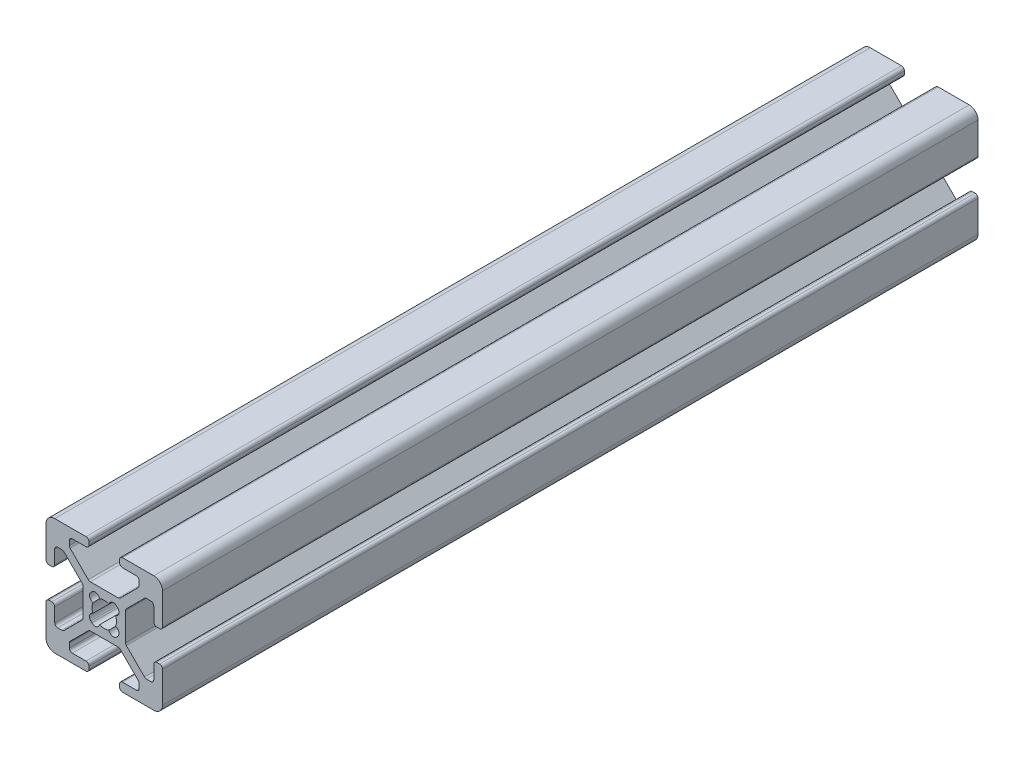
from build123d import *

# Parameters (mm, degrees)
BOSS_EXTRUDE1_DEPTH = 140


with BuildPart() as part:
    # Sketch1 → Boss-Extrude1 (new body)
    with BuildSketch(Plane.XY.offset(4000)):
        with BuildLine():
            Line((10, 3.138), (10, 8.5))
            ThreePointArc((10, 8.5), (9.560660172, 9.560660172), (8.5, 10))
            Line((8.5, 10), (3.138, 10))
            ThreePointArc((3.138, 10), (2.778789755, 9.851210245), (2.63, 9.492))
            Line((2.63, 9.492), (2.63, 9.008))
            ThreePointArc((2.63, 9.008), (2.778789755, 8.648789755), (3.138, 8.5))
            Line((3.138, 8.5), (5.487, 8.5))
            ThreePointArc((5.487, 8.5), (5.846210245, 8.351210245), (5.995, 7.992))
            Line((5.995, 7.992), (5.995, 7.266080661))
            ThreePointArc((5.995, 7.266080661), (5.956330803, 7.071677478), (5.846210245, 6.906870417))
            Line((5.846210245, 6.906870417), (2.743129583, 3.803789755))
            ThreePointArc((2.743129583, 3.803789755), (2.578322522, 3.693669197), (2.383919339, 3.655))
            Line((2.383919339, 3.655), (-2.383919339, 3.655))
            ThreePointArc((-2.383919339, 3.655), (-2.578322522, 3.693669197), (-2.743129583, 3.803789755))
            Line((-2.743129583, 3.803789755), (-5.846210245, 6.906870417))
            ThreePointArc((-5.846210245, 6.906870417), (-5.956330803, 7.071677478), (-5.995, 7.266080661))
            Line((-5.995, 7.266080661), (-5.995, 7.992))
            ThreePointArc((-5.995, 7.992), (-5.846210245, 8.351210245), (-5.487, 8.5))
            Line((-5.487, 8.5), (-3.138, 8.5))
            ThreePointArc((-3.138, 8.5), (-2.778789755, 8.648789755), (-2.63, 9.008))
            Line((-2.63, 9.008), (-2.63, 9.492))
            ThreePointArc((-2.63, 9.492), (-2.778789755, 9.851210245), (-3.138, 10))
            Line((-3.138, 10), (-8.5, 10))
            ThreePointArc((-8.5, 10), (-9.560660172, 9.560660172), (-10, 8.5))
            Line((-10, 8.5), (-10, 3.138))
            ThreePointArc((-10, 3.138), (-9.851210245, 2.778789755), (-9.492, 2.63))
            Line((-9.492, 2.63), (-9.008, 2.63))
            ThreePointArc((-9.008, 2.63), (-8.648789755, 2.778789755), (-8.5, 3.138))
            Line((-8.5, 3.138), (-8.5, 5.487))
            ThreePointArc((-8.5, 5.487), (-8.351210245, 5.846210245), (-7.992, 5.995))
            Line((-7.992, 5.995), (-7.266080661, 5.995))
            ThreePointArc((-7.266080661, 5.995), (-7.071677478, 5.956330803), (-6.906870417, 5.846210245))
            Line((-6.906870417, 5.846210245), (-3.803789755, 2.743129583))
            ThreePointArc((-3.803789755, 2.743129583), (-3.693669197, 2.578322522), (-3.655, 2.383919339))
            Line((-3.655, 2.383919339), (-3.655, -2.383919339))
            ThreePointArc((-3.655, -2.383919339), (-3.693669197, -2.578322522), (-3.803789755, -2.743129583))
            Line((-3.803789755, -2.743129583), (-6.906870417, -5.846210245))
            ThreePointArc((-6.906870417, -5.846210245), (-7.071677478, -5.956330803), (-7.266080661, -5.995))
            Line((-7.266080661, -5.995), (-7.992, -5.995))
            ThreePointArc((-7.992, -5.995), (-8.351210245, -5.846210245), (-8.5, -5.487))
            Line((-8.5, -5.487), (-8.5, -3.138))
            ThreePointArc((-8.5, -3.138), (-8.648789755, -2.778789755), (-9.008, -2.63))
            Line((-9.008, -2.63), (-9.492, -2.63))
            ThreePointArc((-9.492, -2.63), (-9.851210245, -2.778789755), (-10, -3.138))
            Line((-10, -3.138), (-10, -8.5))
            ThreePointArc((-10, -8.5), (-9.560660172, -9.560660172), (-8.5, -10))
            Line((-8.5, -10), (-3.138, -10))
            ThreePointArc((-3.138, -10), (-2.778789755, -9.851210245), (-2.63, -9.492))
            Line((-2.63, -9.492), (-2.63, -9.008))
            ThreePointArc((-2.63, -9.008), (-2.778789755, -8.648789755), (-3.138, -8.5))
            Line((-3.138, -8.5), (-5.487, -8.5))
            ThreePointArc((-5.487, -8.5), (-5.846210245, -8.351210245), (-5.995, -7.992))
            Line((-5.995, -7.992), (-5.995, -7.266080661))
            ThreePointArc((-5.995, -7.266080661), (-5.956330803, -7.071677478), (-5.846210245, -6.906870417))
            Line((-5.846210245, -6.906870417), (-2.743129583, -3.803789755))
            ThreePointArc((-2.743129583, -3.803789755), (-2.578322522, -3.693669197), (-2.383919339, -3.655))
            Line((-2.383919339, -3.655), (2.383919339, -3.655))
            ThreePointArc((2.383919339, -3.655), (2.578322522, -3.693669197), (2.743129583, -3.803789755))
            Line((2.743129583, -3.803789755), (5.846210245, -6.906870417))
            ThreePointArc((5.846210245, -6.906870417), (5.956330803, -7.071677478), (5.995, -7.266080661))
            Line((5.995, -7.266080661), (5.995, -7.992))
            ThreePointArc((5.995, -7.992), (5.846210245, -8.351210245), (5.487, -8.5))
            Line((5.487, -8.5), (3.138, -8.5))
            ThreePointArc((3.138, -8.5), (2.778789755, -8.648789755), (2.63, -9.008))
            Line((2.63, -9.008), (2.63, -9.492))
            ThreePointArc((2.63, -9.492), (2.778789755, -9.851210245), (3.138, -10))
            Line((3.138, -10), (8.5, -10))
            ThreePointArc((8.5, -10), (9.560660172, -9.560660172), (10, -8.5))
            Line((10, -8.5), (10, -3.138))
            ThreePointArc((10, -3.138), (9.851210245, -2.778789755), (9.492, -2.63))
            Line((9.492, -2.63), (9.008, -2.63))
            ThreePointArc((9.008, -2.63), (8.648789755, -2.778789755), (8.5, -3.138))
            Line((8.5, -3.138), (8.5, -5.487))
            ThreePointArc((8.5, -5.487), (8.351210245, -5.846210245), (7.992, -5.995))
            Line((7.992, -5.995), (7.266080661, -5.995))
            ThreePointArc((7.266080661, -5.995), (7.071677478, -5.956330803), (6.906870417, -5.846210245))
            Line((6.906870417, -5.846210245), (3.803789755, -2.743129583))
            ThreePointArc((3.803789755, -2.743129583), (3.693669197, -2.578322522), (3.655, -2.383919339))
            Line((3.655, -2.383919339), (3.655, 2.383919339))
            ThreePointArc((3.655, 2.383919339), (3.693669197, 2.578322522), (3.803789755, 2.743129583))
            Line((3.803789755, 2.743129583), (6.906870417, 5.846210245))
            ThreePointArc((6.906870417, 5.846210245), (7.071677478, 5.956330803), (7.266080661, 5.995))
            Line((7.266080661, 5.995), (7.992, 5.995))
            ThreePointArc((7.992, 5.995), (8.351210245, 5.846210245), (8.5, 5.487))
            Line((8.5, 5.487), (8.5, 3.138))
            ThreePointArc((8.5, 3.138), (8.648789755, 2.778789755), (9.008, 2.63))
            Line((9.008, 2.63), (9.492, 2.63))
            ThreePointArc((9.492, 2.63), (9.851210245, 2.778789755), (10, 3.138))
        make_face()
        with BuildLine():
            Line((-2.124900844, -2.304505966), (-2.304505966, -2.124900844))
            ThreePointArc((-2.304505966, -2.124900844), (-2.505938017, -1.356467811), (-1.935133506, -0.803976718))
            ThreePointArc((-1.935133506, -0.803976718), (-2.0955, 0), (-1.935133506, 0.803976718))
            ThreePointArc((-1.935133506, 0.803976718), (-2.505938017, 1.356467811), (-2.304505966, 2.124900844))
            Line((-2.304505966, 2.124900844), (-2.124900844, 2.304505966))
            ThreePointArc((-2.124900844, 2.304505966), (-1.356467811, 2.505938017), (-0.803976718, 1.935133506))
            ThreePointArc((-0.803976718, 1.935133506), (0, 2.0955), (0.803976718, 1.935133506))
            ThreePointArc((0.803976718, 1.935133506), (1.356467811, 2.505938017), (2.124900844, 2.304505966))
            Line((2.124900844, 2.304505966), (2.304505966, 2.124900844))
            ThreePointArc((2.304505966, 2.124900844), (2.505938017, 1.356467811), (1.935133506, 0.803976718))
            ThreePointArc((1.935133506, 0.803976718), (2.0955, 0), (1.935133506, -0.803976718))
            ThreePointArc((1.935133506, -0.803976718), (2.505938017, -1.356467811), (2.304505966, -2.124900844))
            Line((2.304505966, -2.124900844), (2.124900844, -2.304505966))
            ThreePointArc((2.124900844, -2.304505966), (1.356467811, -2.505938017), (0.803976718, -1.935133506))
            ThreePointArc((0.803976718, -1.935133506), (0, -2.0955), (-0.803976718, -1.935133506))
            ThreePointArc((-0.803976718, -1.935133506), (-1.356467811, -2.505938017), (-2.124900844, -2.304505966))
        make_face(mode=Mode.SUBTRACT)
    extrude(amount=-BOSS_EXTRUDE1_DEPTH)


solid = part.part
